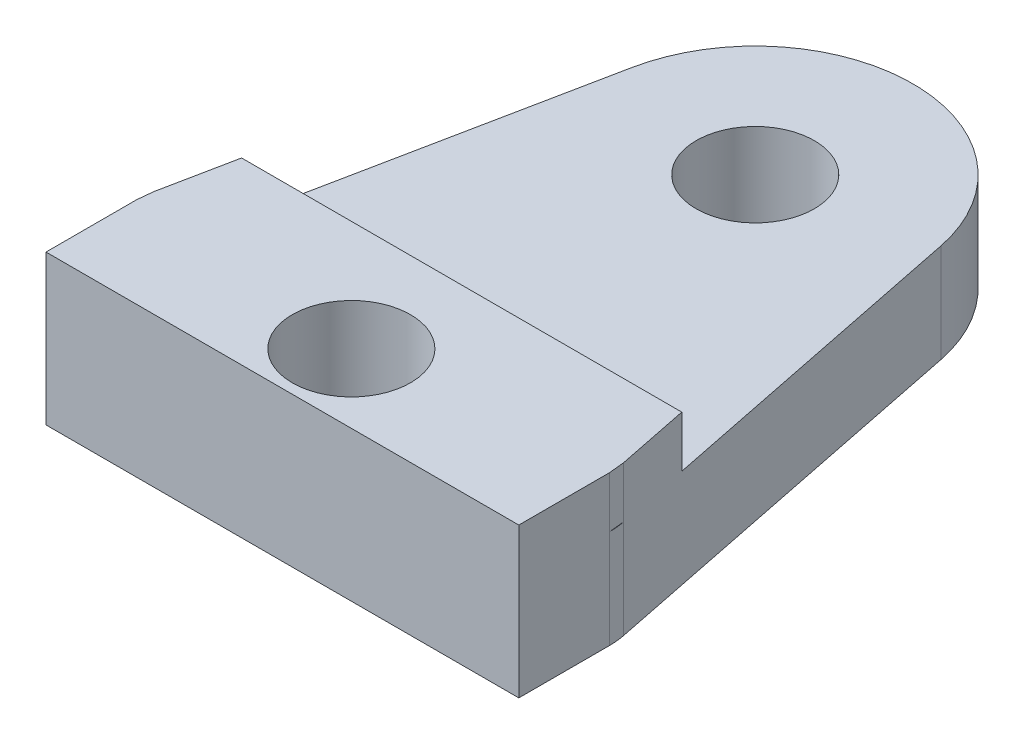
from build123d import *

# Parameters (mm, degrees)
SKETCH1_R           = 1.5
BOSS_EXTRUDE1_DEPTH = 2.5
FILLET2_R           = 2
BOSS_EXTRUDE2_DEPTH = 1.3
SKETCH3_R           = 1.5
CUT_EXTRUDE1_DEPTH  = 3.8


with BuildPart() as part:
    # Sketch1 → Boss-Extrude1 (new body)
    with BuildSketch(Plane(origin=(0, 0, 0), x_dir=(1, 0, 0), z_dir=(0, 1, 0))):
        with BuildLine():
            Line((2.079207921, 12.792079208), (0, 2.5))
            Line((0, 2.5), (0, 0))
            Line((0, 0), (12, 0))
            Line((12, 0), (12, 2.5))
            Line((12, 2.5), (9.920792079, 12.792079208))
            ThreePointArc((9.920792079, 12.792079208), (6, 16), (2.079207921, 12.792079208))
        make_face()
        with Locations((6, 12)):
            Circle(SKETCH1_R, mode=Mode.SUBTRACT)
    extrude(amount=BOSS_EXTRUDE1_DEPTH)

    # Fillet2
    fillet2_edges = [part.edges().sort_by_distance(p)[0] for p in [
        (0, 1.25, -2.5),
        (12, 1.25, -2.5),
    ]]
    fillet(fillet2_edges, radius=FILLET2_R)

    # Sketch2 → Boss-Extrude2 (add)
    with BuildSketch(Plane(origin=(0, 2.5, 0), x_dir=(1, 0, 0), z_dir=(0, 1, 0))):
        Polygon((0.414141414, 4.55), (11.585858586, 4.55), (11.96039604, 2.696039604), (12, 2.3), (12, 0), (0, 0), (0, 2.3), (0.03960396, 2.696039604), align=None)
    extrude(amount=BOSS_EXTRUDE2_DEPTH)

    # Sketch3 → Cut-Extrude1 (cut)
    with BuildSketch(Plane(origin=(0, 3.8, 0), x_dir=(1, 0, 0), z_dir=(0, 1, 0))):
        with Locations((6, 1.75)):
            Circle(SKETCH3_R)
    extrude(amount=-CUT_EXTRUDE1_DEPTH, mode=Mode.SUBTRACT)


solid = part.part
